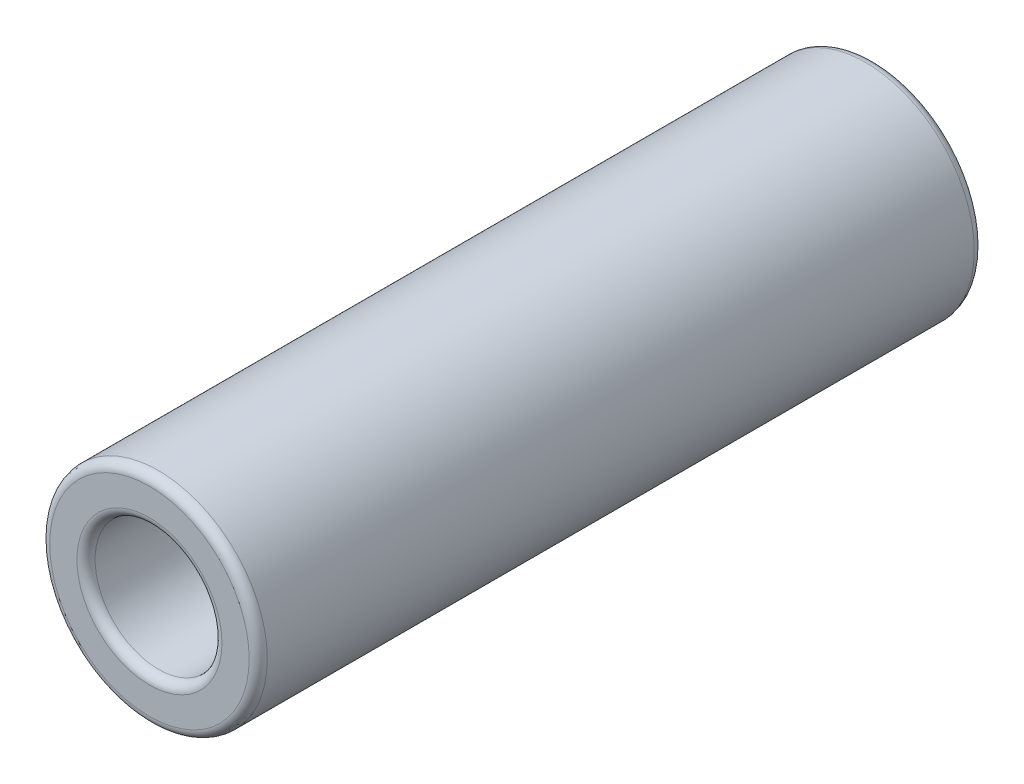
from build123d import *

# Parameters (mm, degrees)
SZKIC1_R                    = 6
SZKIC1_R_2                  = 3.5
DODANIE_WYCI_GNI_CIE1_DEPTH = 40
ZAOKR_GLENIE1_R             = 0.5
ZAOKR_GLENIE2_R             = 0.5


with BuildPart() as part:
    # Szkic1 → Dodanie-wyciągnięcie1 (new body)
    with BuildSketch(Plane.XY):
        Circle(SZKIC1_R)
        Circle(SZKIC1_R_2, mode=Mode.SUBTRACT)
    extrude(amount=-DODANIE_WYCI_GNI_CIE1_DEPTH)

    # Zaokrąglenie1
    zaokr_glenie1_edges = [part.edges().sort_by_distance(p)[0] for p in [
        (-6, 0, 0),
        (-6, 0, -40),
    ]]
    fillet(zaokr_glenie1_edges, radius=ZAOKR_GLENIE1_R)

    # Zaokrąglenie2
    zaokr_glenie2_edges = [part.edges().sort_by_distance(p)[0] for p in [
        (-3.5, 0, -40),
        (-3.5, 0, 0),
    ]]
    fillet(zaokr_glenie2_edges, radius=ZAOKR_GLENIE2_R)


solid = part.part
